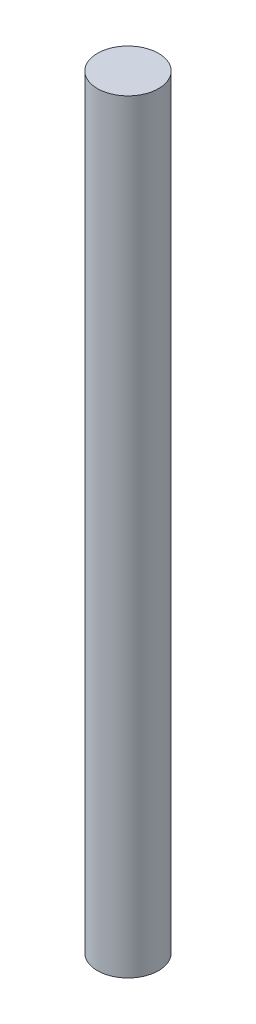
from build123d import *

# Parameters (mm, degrees)
SKETCH1_R           = 3
BOSS_EXTRUDE1_DEPTH = 75


with BuildPart() as part:
    # Sketch1 → Boss-Extrude1 (new body)
    with BuildSketch(Plane(origin=(0, 0, 0), x_dir=(1, 0, 0), z_dir=(0, 1, 0))):
        with Locations(Location((0, 0, 0), (0, 0, 270))):  # turned: the seam where the file's is
            Circle(SKETCH1_R)
    extrude(amount=BOSS_EXTRUDE1_DEPTH)


solid = part.part
